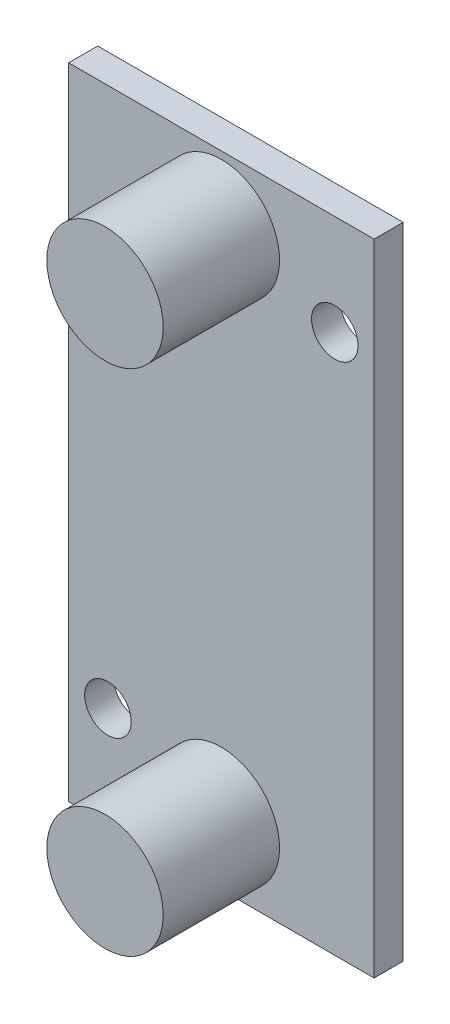
from build123d import *

# Parameters (mm, degrees)
SKETCH1_W           = 21
SKETCH1_H           = 44
BOSS_EXTRUDE1_DEPTH = 2
SKETCH2_R           = 1.6
CUT_EXTRUDE1_DEPTH  = 3
SKETCH3_R           = 4
BOSS_EXTRUDE2_DEPTH = 8


with BuildPart() as part:
    # Sketch1 → Boss-Extrude1 (new body)
    with BuildSketch(Plane.XY):
        with Locations((10.5, 22)):
            Rectangle(SKETCH1_W, SKETCH1_H)
    extrude(amount=BOSS_EXTRUDE1_DEPTH)

    # Sketch2 → Cut-Extrude1 (cut, through all)
    with BuildSketch(Plane.XY.offset(2)):
        with Locations((18.3, 37.1)):
            Circle(SKETCH2_R)
        with Locations((2.7, 6.9)):
            Circle(SKETCH2_R)
    extrude(amount=-CUT_EXTRUDE1_DEPTH, mode=Mode.SUBTRACT)

    # Sketch3 → Boss-Extrude2 (add)
    with BuildSketch(Plane.XY.offset(2)):
        with Locations((10.5, 39.5)):
            Circle(SKETCH3_R)
        with Locations((10.5, 4.5)):
            Circle(SKETCH3_R)
    extrude(amount=BOSS_EXTRUDE2_DEPTH)


solid = part.part
